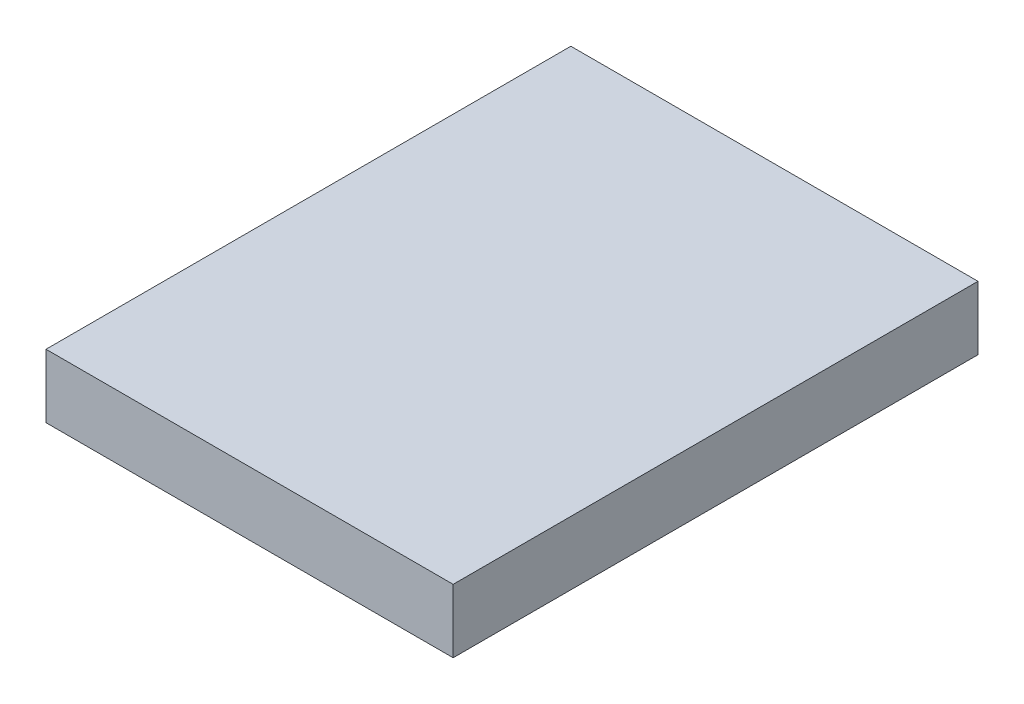
from build123d import *

# Parameters (mm, degrees)
SKETCH1_W                     = 32.512
SKETCH1_H                     = 41.91
BOSS_EXTRUDE1_DEPTH           = 5.08
TAP_DRILL_FOR_4_48_TAP1_D     = 2.3749
TAP_DRILL_FOR_4_48_TAP1_DEPTH = 10.16
TAP_DRILL_FOR_4_48_TAP1_TIP   = 0.713491942


with BuildPart() as part:
    # Sketch1 → Boss-Extrude1 (new body)
    with BuildSketch(Plane(origin=(0, 0, 0), x_dir=(1, 0, 0), z_dir=(0, 1, 0))):
        with Locations((-1.010735751, -13.163911917)):
            Rectangle(SKETCH1_W, SKETCH1_H)
    extrude(amount=BOSS_EXTRUDE1_DEPTH)

    # Tap Drill for #4-48 Tap1
    with Locations(Plane(origin=(0, 0, -7.791088083), x_dir=(-1, 0, 0), z_dir=(0, 0, -1))):
        with Locations((12.186735751, 2.718353123), (-10.673264249, 2.718353123)):
            Hole(TAP_DRILL_FOR_4_48_TAP1_D / 2, depth=TAP_DRILL_FOR_4_48_TAP1_DEPTH)
            with Locations((0, 0, -(TAP_DRILL_FOR_4_48_TAP1_DEPTH + TAP_DRILL_FOR_4_48_TAP1_TIP / 2))):  # 118° drill point
                Cone(0, TAP_DRILL_FOR_4_48_TAP1_D / 2, TAP_DRILL_FOR_4_48_TAP1_TIP, mode=Mode.SUBTRACT)


solid = part.part
